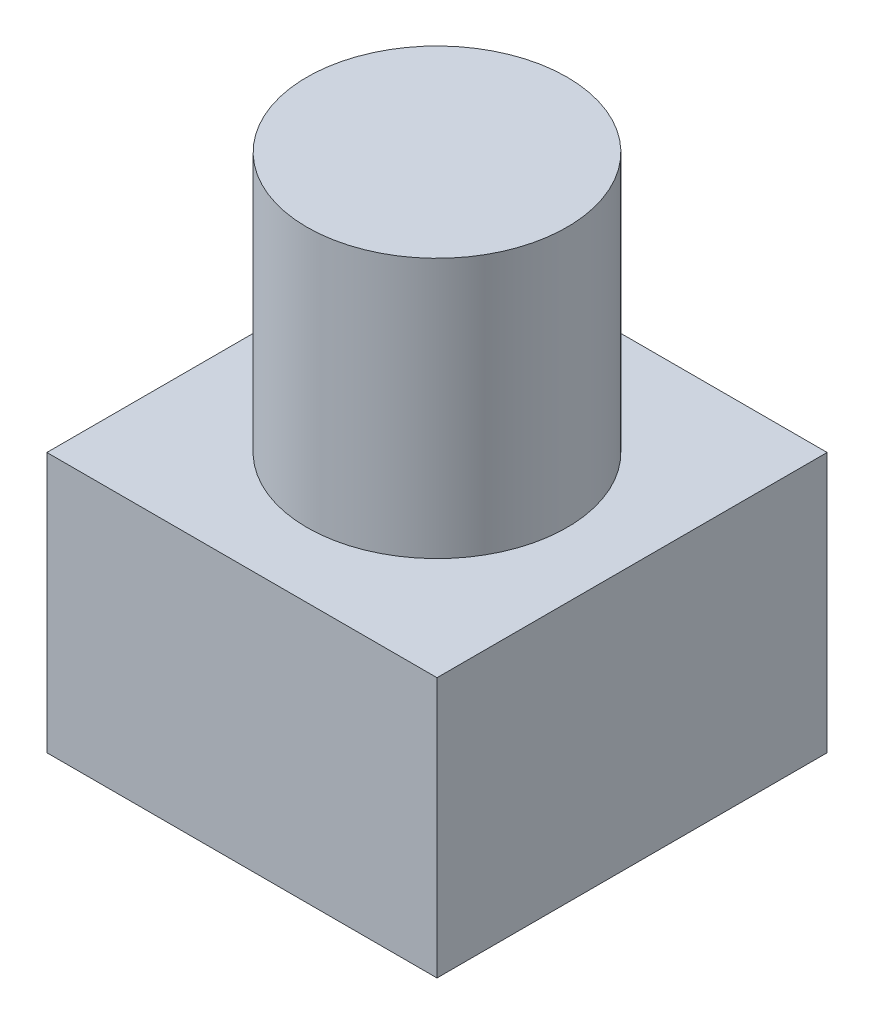
from build123d import *

# Parameters (mm, degrees)
SZKIC2_R                    = 5
DODANIE_WYCI_GNI_CIE1_DEPTH = 20
SZKIC2_3_W                  = 15
SZKIC2_3_H                  = 15
SZKIC2_3_R                  = 5
DODANIE_WYCI_GNI_CIE2_DEPTH = 10


with BuildPart() as part:
    # Szkic2 → Dodanie-wyci_gni_cie1 (new body)
    with BuildSketch(Plane(origin=(0, 0, 0), x_dir=(1, 0, 0), z_dir=(0, 1, 0))):
        Circle(SZKIC2_R)
    extrude(amount=DODANIE_WYCI_GNI_CIE1_DEPTH)

    # Szkic2_3 → Dodanie-wyci_gni_cie2 (add)
    with BuildSketch(Plane(origin=(0, 0, 0), x_dir=(1, 0, 0), z_dir=(0, 1, 0))):
        Rectangle(SZKIC2_3_W, SZKIC2_3_H)
        Circle(SZKIC2_3_R, mode=Mode.SUBTRACT)
    extrude(amount=DODANIE_WYCI_GNI_CIE2_DEPTH)


solid = part.part
